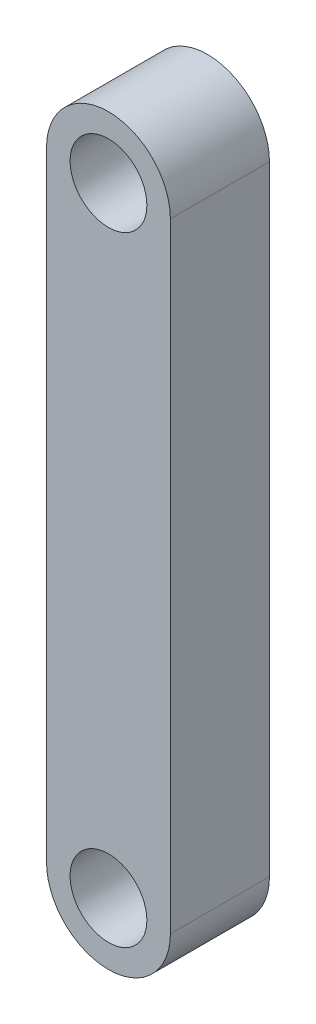
from build123d import *

# Parameters (mm, degrees)
SKETCH_1_R      = 1.55
EXTRUDE_1_DEPTH = 4


with BuildPart() as part:
    # 草图1 → 凸台-拉伸1 (new body)
    with BuildSketch(Plane.XY):
        with BuildLine():
            Line((-2.5, -12.5), (-2.5, 12.5))
            ThreePointArc((-2.5, 12.5), (0, 15), (2.5, 12.5))
            Line((2.5, 12.5), (2.5, -12.5))
            ThreePointArc((2.5, -12.5), (0, -15), (-2.5, -12.5))
        make_face()
        with Locations((0, 12.5)):
            Circle(SKETCH_1_R, mode=Mode.SUBTRACT)
        with Locations((0, -12.5)):
            Circle(SKETCH_1_R, mode=Mode.SUBTRACT)
    extrude(amount=EXTRUDE_1_DEPTH)


solid = part.part
